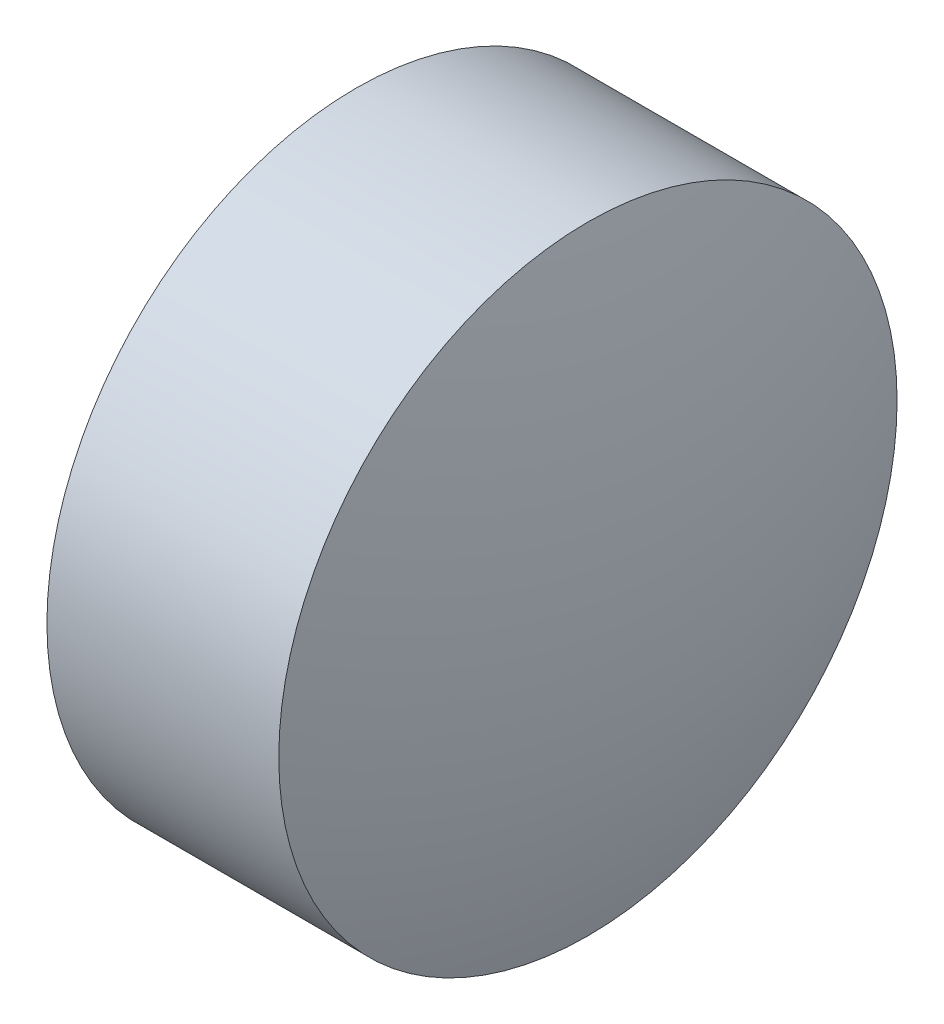
from build123d import *


with BuildPart() as part:
    # 草图1 → 旋转1 (revolve)
    with BuildSketch(Plane.XY):
        with BuildLine():
            Line((382.966706532, 60.204863237), (382.966706532, 62.204863237))
            Line((382.966706532, 62.204863237), (384.466706532, 62.204863237))
            ThreePointArc((384.466706532, 62.204863237), (384.691289337, 61.216050658), (384.766706532, 60.204863237))
            Line((384.766706532, 60.204863237), (382.966706532, 60.204863237))
        make_face()
    revolve(axis=Axis((382.538599838, 60.204863237, 0), (1, 0, 0)))


solid = part.part
